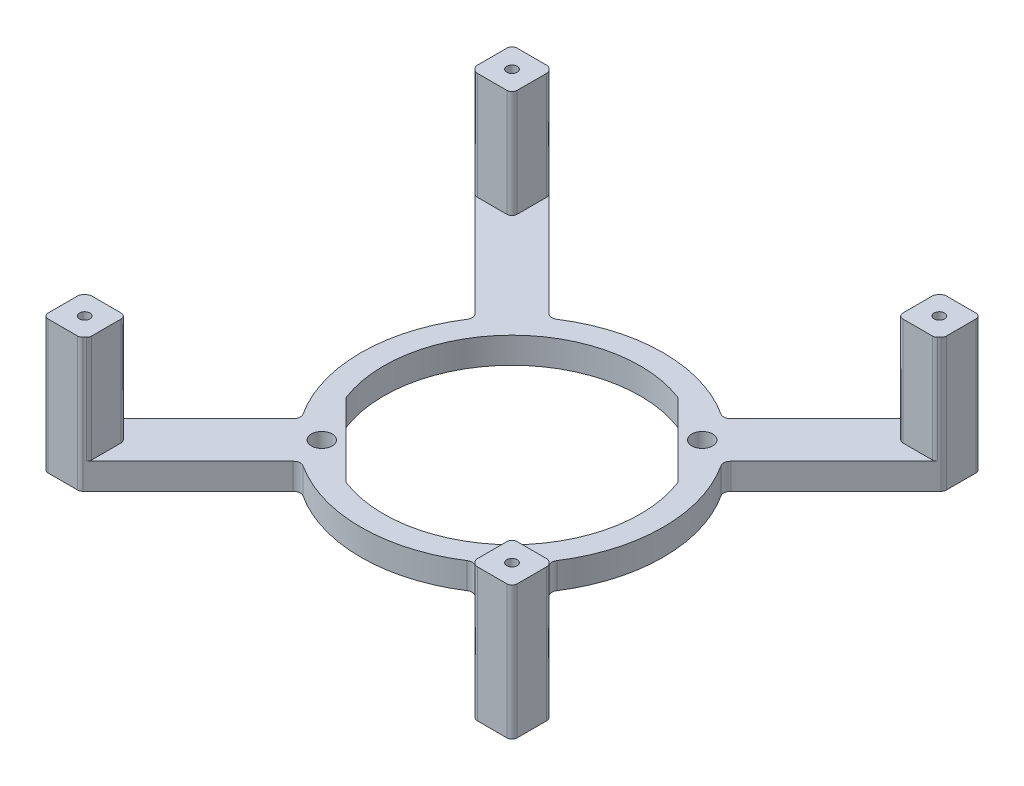
from build123d import *

# Parameters (mm, degrees)
BOSS_EXTRUDE1_DEPTH         = 5
TAP_DRILL_FOR_M4X0_7_TAP1_D = 4
BOSS_EXTRUDE2_DEPTH         = 20.6
CIRPATTERN1_COUNT           = 4


with BuildPart() as part:
    # Sketch1 → Boss-Extrude1 (new body)
    with BuildSketch(Plane(origin=(0, 0, 0), x_dir=(1, 0, 0), z_dir=(0, 1, 0))):
        with BuildLine():
            Line((6, 95), (11.656854249, 95))
            ThreePointArc((11.656854249, 95), (12.039537682, 94.923879533), (12.363961031, 94.707106781))
            Line((12.363961031, 94.707106781), (32.538709783, 74.532358029))
            ThreePointArc((32.538709783, 74.532358029), (33.362638794, 74.138893326), (34.250764856, 74.350802705))
            ThreePointArc((34.250764856, 74.350802705), (50, 79), (65.749235144, 74.350802705))
            ThreePointArc((65.749235144, 74.350802705), (66.637361206, 74.138893326), (67.461290217, 74.532358029))
            Line((67.461290217, 74.532358029), (87.636038969, 94.707106781))
            ThreePointArc((87.636038969, 94.707106781), (87.960462318, 94.923879533), (88.343145751, 95))
            Line((88.343145751, 95), (94, 95))
            ThreePointArc((94, 95), (94.707106781, 94.707106781), (95, 94))
            Line((95, 94), (95, 88.343145751))
            ThreePointArc((95, 88.343145751), (94.923879533, 87.960462318), (94.707106781, 87.636038969))
            Line((94.707106781, 87.636038969), (74.532358029, 67.461290217))
            ThreePointArc((74.532358029, 67.461290217), (74.138893326, 66.637361206), (74.350802705, 65.749235144))
            ThreePointArc((74.350802705, 65.749235144), (79, 50), (74.350802705, 34.250764856))
            ThreePointArc((74.350802705, 34.250764856), (74.138893326, 33.362638794), (74.532358029, 32.538709783))
            Line((74.532358029, 32.538709783), (94.707106781, 12.363961031))
            ThreePointArc((94.707106781, 12.363961031), (94.923879533, 12.039537682), (95, 11.656854249))
            Line((95, 11.656854249), (95, 6))
            ThreePointArc((95, 6), (94.707106781, 5.292893219), (94, 5))
            Line((94, 5), (88.343145751, 5))
            ThreePointArc((88.343145751, 5), (87.960462318, 5.076120467), (87.636038969, 5.292893219))
            Line((87.636038969, 5.292893219), (67.461290217, 25.467641971))
            ThreePointArc((67.461290217, 25.467641971), (66.637361206, 25.861106674), (65.749235144, 25.649197295))
            ThreePointArc((65.749235144, 25.649197295), (50, 21), (34.250764856, 25.649197295))
            ThreePointArc((34.250764856, 25.649197295), (33.362638794, 25.861106674), (32.538709783, 25.467641971))
            Line((32.538709783, 25.467641971), (12.363961031, 5.292893219))
            ThreePointArc((12.363961031, 5.292893219), (12.039537682, 5.076120467), (11.656854249, 5))
            Line((11.656854249, 5), (6, 5))
            ThreePointArc((6, 5), (5.292893219, 5.292893219), (5, 6))
            Line((5, 6), (5, 11.656854249))
            ThreePointArc((5, 11.656854249), (5.076120467, 12.039537682), (5.292893219, 12.363961031))
            Line((5.292893219, 12.363961031), (25.467641971, 32.538709783))
            ThreePointArc((25.467641971, 32.538709783), (25.861106674, 33.362638794), (25.649197295, 34.250764856))
            ThreePointArc((25.649197295, 34.250764856), (21, 50), (25.649197295, 65.749235144))
            ThreePointArc((25.649197295, 65.749235144), (25.861106674, 66.637361206), (25.467641971, 67.461290217))
            Line((25.467641971, 67.461290217), (5.292893219, 87.636038969))
            ThreePointArc((5.292893219, 87.636038969), (5.076120467, 87.960462318), (5, 88.343145751))
            Line((5, 88.343145751), (5, 94))
            ThreePointArc((5, 94), (5.292893219, 94.707106781), (6, 95))
        make_face()
        with BuildLine():
            Line((72.980970389, 58.838834765), (58.838834765, 72.980970389))
            ThreePointArc((58.838834765, 72.980970389), (32.589514654, 67.410485346), (27.019029611, 41.161165235))
            Line((27.019029611, 41.161165235), (41.161165235, 27.019029611))
            ThreePointArc((41.161165235, 27.019029611), (67.410485346, 32.589514654), (72.980970389, 58.838834765))
        make_face(mode=Mode.SUBTRACT)
    extrude(amount=BOSS_EXTRUDE1_DEPTH)

    # Tap Drill for M4x0.7 Tap1 (through all)
    with Locations(Plane(origin=(31.749573978, 5, -31.749573978), x_dir=(0, 0, 1), z_dir=(0, 1, 0))):
        with Locations((0, 0), (-36.500852044, 36.500852044)):
            Hole(TAP_DRILL_FOR_M4X0_7_TAP1_D / 2)

    # Sketch6 → Boss-Extrude2 (add)
    with BuildSketch(Plane(origin=(0, 5, 0), x_dir=(1, 0, 0), z_dir=(0, 1, 0))):
        with BuildLine():
            Line((6, 95), (11.656854249, 95))
            ThreePointArc((11.656854249, 95), (12.039537682, 94.923879533), (12.363961031, 94.707106781))
            Line((12.363961031, 94.707106781), (12.707106781, 94.363961031))
            ThreePointArc((12.707106781, 94.363961031), (12.923879533, 94.039537682), (13, 93.656854249))
            Line((13, 93.656854249), (13, 88))
            ThreePointArc((13, 88), (12.707106781, 87.292893219), (12, 87))
            Line((12, 87), (6.343145751, 87))
            ThreePointArc((6.343145751, 87), (5.960462318, 87.076120467), (5.636038969, 87.292893219))
            Line((5.636038969, 87.292893219), (5.292893219, 87.636038969))
            ThreePointArc((5.292893219, 87.636038969), (5.076120467, 87.960462318), (5, 88.343145751))
            Line((5, 88.343145751), (5, 94))
            ThreePointArc((5, 94), (5.292893219, 94.707106781), (6, 95))
        make_face()
    boss_extrude2 = extrude(amount=BOSS_EXTRUDE2_DEPTH)

    # Sketch9 → Tap Drill for M2x0.4 Tap1 (revolve, cut)
    with BuildSketch(Plane(origin=(9, 25.6, -91), x_dir=(0, 0, 1), z_dir=(1, 0, 0))):
        Polygon((0, 0), (0, 4.600860619), (1, 4), (1, 0), align=None)
    tap_drill_for_m2x0_4_tap1 = revolve(axis=Axis((9, 31.95, -91), (0, -1, 0)), mode=Mode.SUBTRACT)

    # CirPattern1: Boss-Extrude2, Tap Drill for M2x0.4 Tap1 ×4 about axis
    cirpattern1_axis = Axis((50, 5, -50), (0, -1, 0))
    add([boss_extrude2.rotate(cirpattern1_axis, i * 360 / CIRPATTERN1_COUNT) for i in range(1, CIRPATTERN1_COUNT)])
    add([tap_drill_for_m2x0_4_tap1.rotate(cirpattern1_axis, i * 360 / CIRPATTERN1_COUNT) for i in range(1, CIRPATTERN1_COUNT)], mode=Mode.SUBTRACT)


solid = part.part
